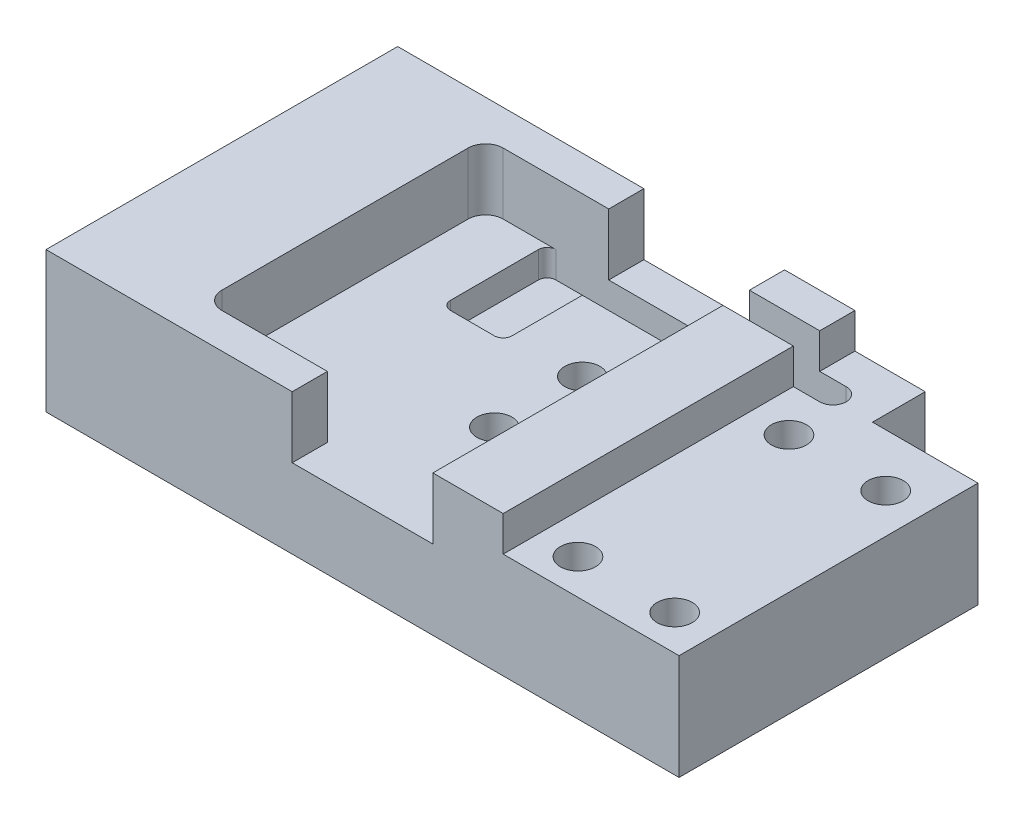
from build123d import *

# Parameters (mm, degrees)
SKETCH_1_W           = 36
SKETCH_1_H           = 20
EXTRUDE_1_DEPTH      = 8
SKETCH_2_W           = 8
SKETCH_2_H           = 20
CUT_EXTRUDE_1_DEPTH  = 3.5
SKETCH_3_R           = 2.5
CUT_EXTRUDE_2_DEPTH  = 4
SKETCH_5_W           = 7
SKETCH_5_H           = 16
CUT_EXTRUDE_4_DEPTH  = 3.5
FILLET_1_R           = 1
SKETCH_6_R           = 1
CUT_EXTRUDE_5_DEPTH  = 5.5
SKETCH_7_W           = 10
SKETCH_7_H           = 20
CUT_EXTRUDE_6_DEPTH  = 2
SKETCH_9_R           = 1
CUT_EXTRUDE_10_DEPTH = 3
SKETCH_10_R          = 2
CUT_EXTRUDE_11_DEPTH = 2.4
SKETCH_11_W          = 6
SKETCH_11_H          = 6
CUT_EXTRUDE_15_DEPTH = 3
SKETCH_14_W          = 3.5
SKETCH_14_H          = 6
CUT_EXTRUDE_17_DEPTH = 1.5
FILLET_4_R           = 0.5
CUT_EXTRUDE_18_DEPTH = 28
FILLET_5_R           = 0.5
FILLET_6_R           = 2


with BuildPart() as part:
    # 草图1 → 凸台-拉伸1 (new body)
    with BuildSketch(Plane(origin=(0, 0, 0), x_dir=(1, 0, 0), z_dir=(0, 1, 0))):
        with Locations((-18, 10)):
            Rectangle(SKETCH_1_W, SKETCH_1_H)
    extrude(amount=EXTRUDE_1_DEPTH)

    # 草图2 → 切除-拉伸1 (cut)
    with BuildSketch(Plane(origin=(0, 8, 0), x_dir=(1, 0, 0), z_dir=(0, 1, 0))):
        with Locations((-18, 10)):
            Rectangle(SKETCH_2_W, SKETCH_2_H)
    extrude(amount=-CUT_EXTRUDE_1_DEPTH, mode=Mode.SUBTRACT)

    # 草图3 → 切除-拉伸2 (cut)
    with BuildSketch(Plane(origin=(0, 0, 0), x_dir=(-1, 0, 0), z_dir=(0, -1, 0))):
        with Locations((8, 10)):
            Circle(SKETCH_3_R)
        with Locations((28, 10)):
            Circle(SKETCH_3_R)
    extrude(amount=-CUT_EXTRUDE_2_DEPTH, mode=Mode.SUBTRACT)

    # 草图5 → 切除-拉伸4 (cut)
    with BuildSketch(Plane(origin=(0, 8, 0), x_dir=(1, 0, 0), z_dir=(0, 1, 0))):
        with Locations((-25.5, 10)):
            Rectangle(SKETCH_5_W, SKETCH_5_H)
    extrude(amount=-CUT_EXTRUDE_4_DEPTH, mode=Mode.SUBTRACT)

    # 圆角1
    fillet_1_edges = [part.edges().sort_by_distance(p)[0] for p in [
        (-29, 6.25, -2),
        (-29, 6.25, -18),
    ]]
    fillet(fillet_1_edges, radius=FILLET_1_R)

    # 草图6 → 切除-拉伸5 (cut, through all)
    with BuildSketch(Plane(origin=(0, 4.5, 0), x_dir=(1, 0, 0), z_dir=(0, 1, 0))):
        with Locations((-18, 12.5)):
            Circle(SKETCH_6_R)
        with Locations((-18, 7.5)):
            Circle(SKETCH_6_R)
    extrude(amount=-CUT_EXTRUDE_5_DEPTH, mode=Mode.SUBTRACT)

    # 草图7 → 切除-拉伸6 (cut)
    with BuildSketch(Plane(origin=(0, 8, 0), x_dir=(1, 0, 0), z_dir=(0, 1, 0))):
        with Locations((-5, 10)):
            Rectangle(SKETCH_7_W, SKETCH_7_H)
    extrude(amount=-CUT_EXTRUDE_6_DEPTH, mode=Mode.SUBTRACT)

    # 草图9 → 切除-拉伸10 (cut)
    with BuildSketch(Plane(origin=(0, 6, 0), x_dir=(1, 0, 0), z_dir=(0, 1, 0))):
        with Locations((-2.25, 2)):
            Circle(SKETCH_9_R)
        with Locations((-7.75, 2)):
            Circle(SKETCH_9_R)
        with Locations((-2.25, 14)):
            Circle(SKETCH_9_R)
        with Locations((-7.75, 14)):
            Circle(SKETCH_9_R)
    extrude(amount=-CUT_EXTRUDE_10_DEPTH, mode=Mode.SUBTRACT)

    # 草图10 → 切除-拉伸11 (cut)
    with BuildSketch(Plane(origin=(0, 0, 0), x_dir=(-1, 0, 0), z_dir=(0, -1, 0))):
        with Locations((18, 12.5)):
            Circle(SKETCH_10_R)
        with Locations((18, 7.5)):
            Circle(SKETCH_10_R)
    extrude(amount=-CUT_EXTRUDE_11_DEPTH, mode=Mode.SUBTRACT)

    # 草图11 → 切除-拉伸15 (cut)
    with BuildSketch(Plane(origin=(0, 0, -20), x_dir=(-1, 0, 0), z_dir=(0, 0, -1))):
        with Locations((3, 3)):
            Rectangle(SKETCH_11_W, SKETCH_11_H)
        with Locations((33, 3)):
            Rectangle(SKETCH_11_W, SKETCH_11_H)
    extrude(amount=-CUT_EXTRUDE_15_DEPTH, mode=Mode.SUBTRACT)

    # 草图14 → 切除-拉伸17 (cut)
    with BuildSketch(Plane(origin=(0, 4.5, 0), x_dir=(1, 0, 0), z_dir=(0, 1, 0))):
        with Locations((-23.75, 15)):
            Rectangle(SKETCH_14_W, SKETCH_14_H)
    extrude(amount=-CUT_EXTRUDE_17_DEPTH, mode=Mode.SUBTRACT)

    # 圆角4
    fillet_4_edges = [part.edges().sort_by_distance(p)[0] for p in [
        (-22, 3.75, -18),
        (-22, 3.75, -12),
        (-25.5, 3.75, -12),
        (-25.5, 3.75, -18),
    ]]
    fillet(fillet_4_edges, radius=FILLET_4_R)

    # 草图15 → 切除-拉伸18 (cut)
    with BuildSketch(Plane(origin=(0, 3, 0), x_dir=(1, 0, 0), z_dir=(0, 1, 0))):
        with BuildLine():
            Line((-25.5, 16.5), (-8.5, 16.5))
            ThreePointArc((-8.5, 16.5), (-7.75, 17.25), (-8.5, 18))
            Line((-8.5, 18), (-25.5, 18))
            Line((-25.5, 18), (-25.5, 16.5))
        make_face()
    extrude(amount=CUT_EXTRUDE_18_DEPTH, mode=Mode.SUBTRACT)

    # 圆角5
    fillet_5_edges = [part.edges().sort_by_distance(p)[0] for p in [
        (-25.5, 3.75, -18),
    ]]
    fillet(fillet_5_edges, radius=FILLET_5_R)

    # 圆角6
    fillet_6_edges = [part.edges().sort_by_distance(p)[0] for p in [
        (-30, 6, -18.5),
    ]]
    fillet(fillet_6_edges, radius=FILLET_6_R)


solid = part.part
